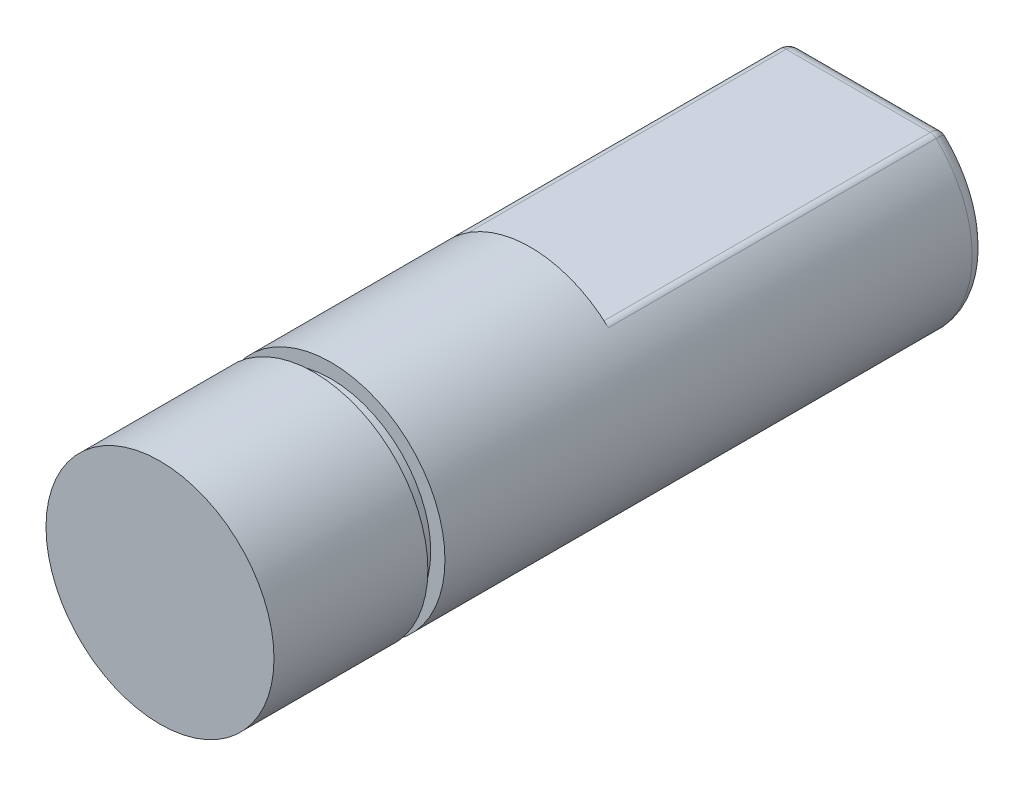
from build123d import *

# Parameters (mm, degrees)
SKETCH1_R               = 4
BOSS_EXTRUDE1_DEPTH     = 25
SKETCH2_W               = 12
SKETCH2_H               = 1
CUT_EXTRUDE1_DEPTH      = 5
CUT_EXTRUDE1_DEPTH_BACK = 5
SKETCH3_W               = 0.6
SKETCH3_H               = 0.5
SKETCH4_R               = 1.5
CUT_EXTRUDE2_DEPTH      = 3
FILLET1_R               = 0.5
FILLET2_R               = 0.3


with BuildPart() as part:
    # Sketch1 → Boss-Extrude1 (new body)
    with BuildSketch(Plane.XY):
        Circle(SKETCH1_R)
    extrude(amount=BOSS_EXTRUDE1_DEPTH)

    # Sketch2 → Cut-Extrude1 (cut, two sides)
    with BuildSketch(Plane(origin=(0, 0, 0), x_dir=(0, 0, -1), z_dir=(1, 0, 0))) as cut_extrude1_sk:
        with Locations((-6, 3.5)):
            Rectangle(SKETCH2_W, SKETCH2_H)
    extrude(amount=CUT_EXTRUDE1_DEPTH, mode=Mode.SUBTRACT)
    extrude(cut_extrude1_sk.sketch, amount=-CUT_EXTRUDE1_DEPTH_BACK, mode=Mode.SUBTRACT)

    # Sketch3 → Cut-Revolve1 (revolve, cut)
    with BuildSketch(Plane(origin=(0, 0, 0), x_dir=(0, 0, -1), z_dir=(1, 0, 0))):
        with Locations((-19.3, 3.75)):
            Rectangle(SKETCH3_W, SKETCH3_H)
    revolve(axis=Axis((0, 0, 0), (0, 0, 1)), mode=Mode.SUBTRACT)

    # Sketch4 → Cut-Extrude2 (cut)
    with BuildSketch(Plane(origin=(0, 0, 0), x_dir=(-1, 0, 0), z_dir=(0, 0, -1))):
        Circle(SKETCH4_R)
    extrude(amount=-CUT_EXTRUDE2_DEPTH, mode=Mode.SUBTRACT)

    # Fillet1
    fillet1_edges = [part.edges().sort_by_distance(p)[0] for p in [
        (1.5, 0, 0),
        (-1.645751311, -3.645751311, 0),
        (0, 3, 0),
    ]]
    fillet(fillet1_edges, radius=FILLET1_R)

    # Fillet2
    fillet2_edges = [part.edges().sort_by_distance(p)[0] for p in [
        (2.645751311, 3, 6.25),
        (-2.587228032, 2.846874445, 0.139891517),
        (2.587228032, 2.846874445, 0.139891517),
        (-2.645751311, 3, 6.25),
    ]]
    fillet(fillet2_edges, radius=FILLET2_R)


solid = part.part
